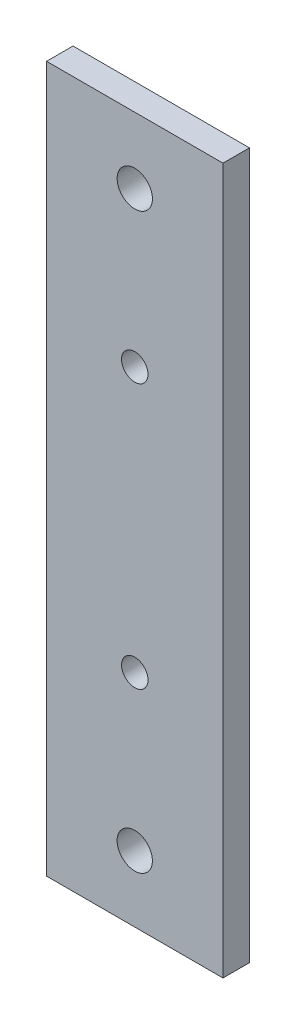
from build123d import *

# Parameters (mm, degrees)
ESQUISSE1_W        = 20
ESQUISSE1_H        = 80
ESQUISSE1_R        = 1.5
ESQUISSE1_R_2      = 2
BOSS_EXTRU_1_DEPTH = 3


with BuildPart() as part:
    # Esquisse1 → Boss.-Extru.1 (new body)
    with BuildSketch(Plane.XY):
        with Locations((10, 40)):
            Rectangle(ESQUISSE1_W, ESQUISSE1_H)
        with Locations((10, 55)):
            Circle(ESQUISSE1_R, mode=Mode.SUBTRACT)
        with Locations((10, 25)):
            Circle(ESQUISSE1_R, mode=Mode.SUBTRACT)
        with Locations((10, 72.5)):
            Circle(ESQUISSE1_R_2, mode=Mode.SUBTRACT)
        with Locations((10, 7.5)):
            Circle(ESQUISSE1_R_2, mode=Mode.SUBTRACT)
    extrude(amount=BOSS_EXTRU_1_DEPTH)


solid = part.part
